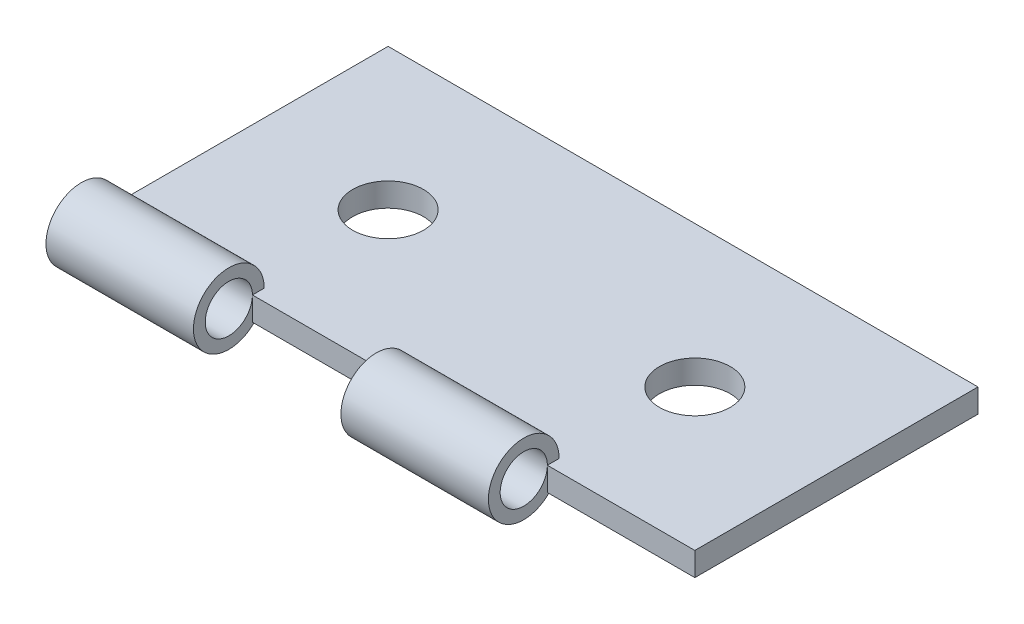
from build123d import *

# Parameters (mm, degrees)
SKETCH1_W           = 25
SKETCH1_H           = 12
SKETCH1_R           = 1.5
BOSS_EXTRUDE1_DEPTH = 1
SKETCH2_R           = 1.5
SKETCH2_R_2         = 1
BOSS_EXTRUDE2_DEPTH = 6.25
BOSS_EXTRUDE3_START = 12.5
SKETCH3_R           = 1.5
SKETCH3_R_2         = 1
BOSS_EXTRUDE3_DEPTH = 6.25


with BuildPart() as part:
    # Sketch1 → Boss-Extrude1 (new body)
    with BuildSketch(Plane(origin=(0, 0, 0), x_dir=(1, 0, 0), z_dir=(0, 1, 0))):
        with Locations((12.5, 6)):
            Rectangle(SKETCH1_W, SKETCH1_H)
        with Locations((6, 6)):
            Circle(SKETCH1_R, mode=Mode.SUBTRACT)
        with Locations((19, 6)):
            Circle(SKETCH1_R, mode=Mode.SUBTRACT)
    extrude(amount=BOSS_EXTRUDE1_DEPTH)

    # Sketch2 → Boss-Extrude2 (add)
    with BuildSketch(Plane(origin=(0, 0, 0), x_dir=(0, 0, -1), z_dir=(1, 0, 0))):
        with Locations((-1, 1)):
            Circle(SKETCH2_R)
        with Locations((-1, 1)):
            Circle(SKETCH2_R_2, mode=Mode.SUBTRACT)
    extrude(amount=BOSS_EXTRUDE2_DEPTH)

    # Sketch3 → Boss-Extrude3 (add)
    with BuildSketch(Plane(origin=(0, 0, 0), x_dir=(0, 0, -1), z_dir=(1, 0, 0)).offset(BOSS_EXTRUDE3_START)):
        with Locations((-1, 1)):
            Circle(SKETCH3_R)
        with Locations((-1, 1)):
            Circle(SKETCH3_R_2, mode=Mode.SUBTRACT)
    extrude(amount=BOSS_EXTRUDE3_DEPTH)


solid = part.part
